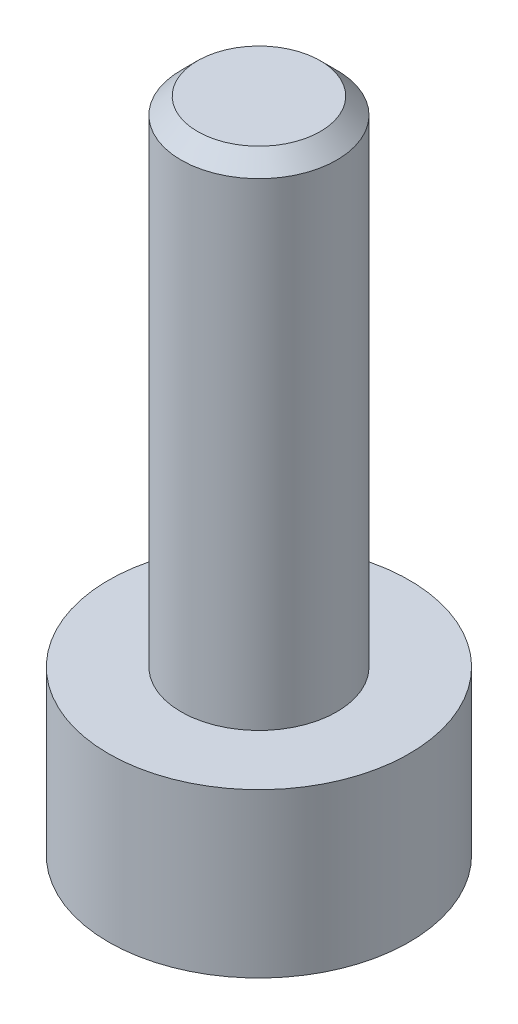
from build123d import *

# Parameters (mm, degrees)
SKETCH1_R           = 1.825
BOSS_EXTRUDE1_DEPTH = 1.98
SKETCH2_R           = 0.945
BOSS_EXTRUDE2_DEPTH = 6
CUT_EXTRUDE1_DEPTH  = 1
CHAMFER1_SIZE       = 0.2


with BuildPart() as part:
    # Sketch1 → Boss-Extrude1 (new body)
    with BuildSketch(Plane(origin=(0, 0, 0), x_dir=(1, 0, 0), z_dir=(0, 1, 0))):
        Circle(SKETCH1_R)
    extrude(amount=BOSS_EXTRUDE1_DEPTH)

    # Sketch2 → Boss-Extrude2 (add)
    with BuildSketch(Plane(origin=(0, 1.98, 0), x_dir=(1, 0, 0), z_dir=(0, 1, 0))):
        Circle(SKETCH2_R)
    extrude(amount=BOSS_EXTRUDE2_DEPTH)

    # Sketch3 → Cut-Extrude1 (cut)
    with BuildSketch(Plane.XZ):
        Polygon((0.458993464, -0.795), (0.917986928, 0), (0.458993464, 0.795), (-0.458993464, 0.795), (-0.917986928, 0), (-0.458993464, -0.795), align=None)
    extrude(amount=-CUT_EXTRUDE1_DEPTH, mode=Mode.SUBTRACT)

    # Chamfer1
    chamfer1_edges = [part.edges().sort_by_distance(p)[0] for p in [
        (-0.945, 7.98, 0),
    ]]
    chamfer(chamfer1_edges, length=CHAMFER1_SIZE)


solid = part.part
